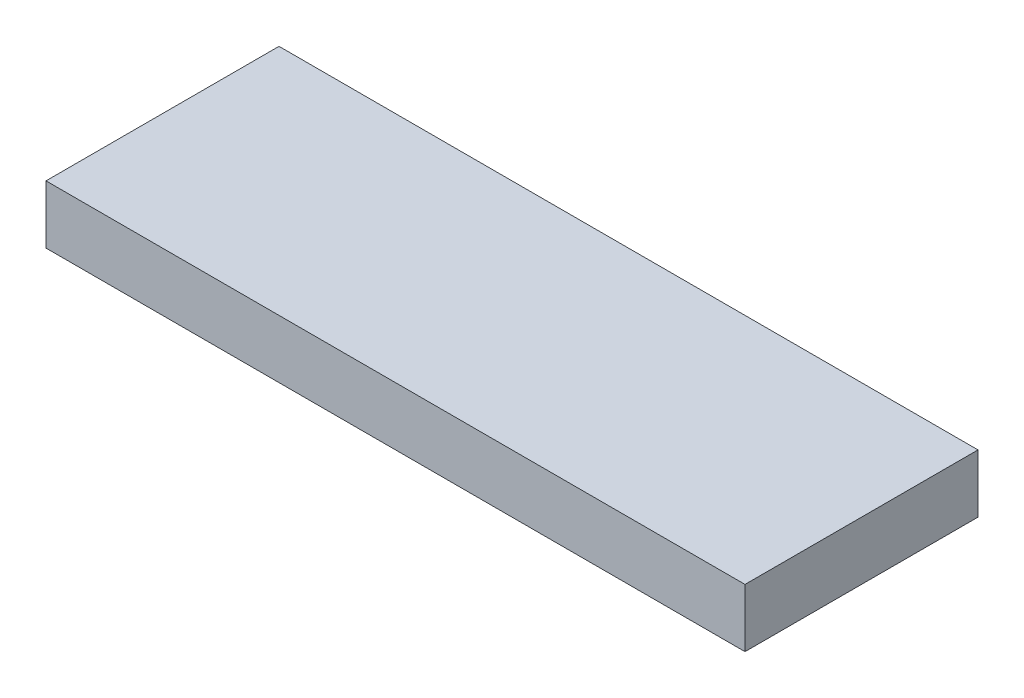
from build123d import *

# Parameters (mm, degrees)
SKETCH1_W           = 76.2
SKETCH1_H           = 25.4
BOSS_EXTRUDE1_DEPTH = 6.35


with BuildPart() as part:
    # Sketch1 → Boss-Extrude1 (new body)
    with BuildSketch(Plane(origin=(0, 0, 0), x_dir=(1, 0, 0), z_dir=(0, 1, 0))):
        with Locations((38.1, 12.7)):
            Rectangle(SKETCH1_W, SKETCH1_H)
    extrude(amount=BOSS_EXTRUDE1_DEPTH)


solid = part.part
